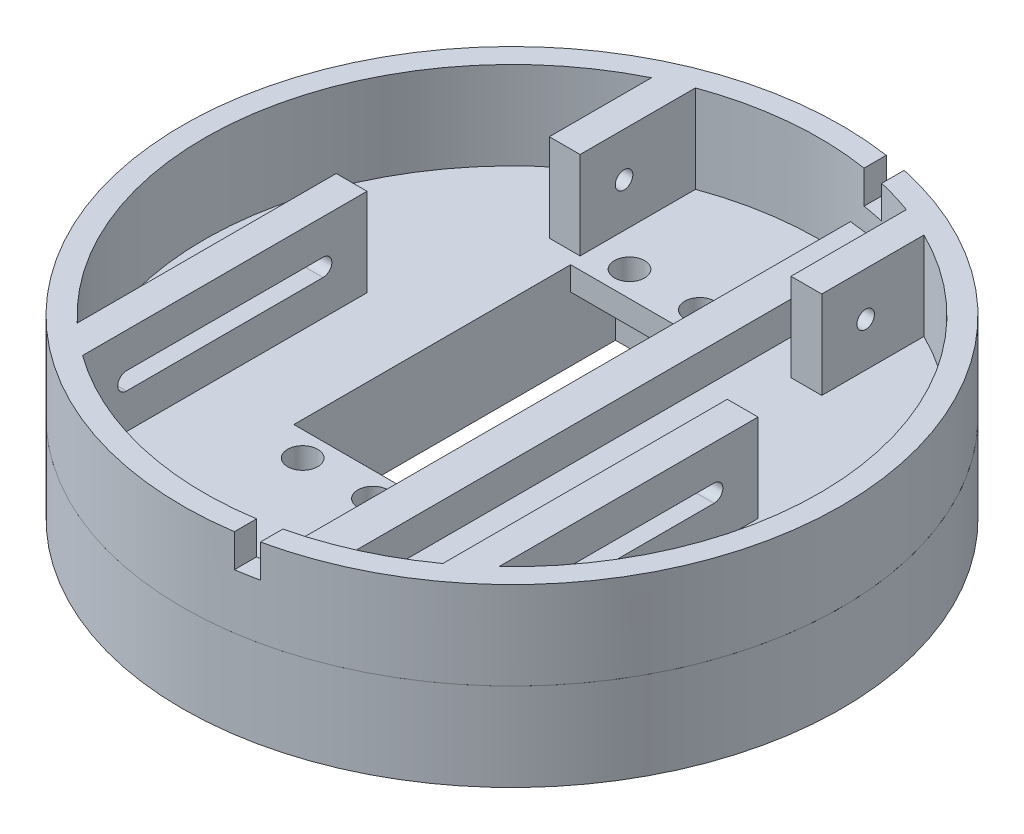
from build123d import *

# Parameters (mm, degrees)
SKETCH1_R           = 47.625
BOSS_EXTRUDE1_DEPTH = 12.7
SKETCH2_R           = 47.625
BOSS_EXTRUDE4_DEPTH = 12.7
CUT_EXTRUDE8_START  = -34.925
SKETCH8_R           = 1.27
CUT_EXTRUDE8_DEPTH  = 4.445
CUT_EXTRUDE15_DEPTH = 4.445
BOSS_EXTRUDE5_DEPTH = 4.7625
CUT_EXTRUDE10_DEPTH = 4.7625
SKETCH14_W          = 19.812
SKETCH14_H          = 52.959
CUT_EXTRUDE11_DEPTH = 9.275815586
SKETCH15_W          = 19.812
SKETCH15_H          = 40.005
CUT_EXTRUDE12_DEPTH = 8.186684
CUT_EXTRUDE13_START = -3.424185
SKETCH16_R          = 2.1844
CUT_EXTRUDE13_DEPTH = 3.424185


with BuildPart() as part:
    # Sketch1 → Boss-Extrude1 (new body)
    with BuildSketch(Plane(origin=(0, 0, 0), x_dir=(1, 0, 0), z_dir=(0, 1, 0))):
        Circle(SKETCH1_R)
    extrude(amount=-BOSS_EXTRUDE1_DEPTH)

    # Sketch14 → Cut-Extrude11 (cut)
    with BuildSketch(Plane.XZ.offset(12.7)):
        with Locations((-4.92125, -3.302)):
            Rectangle(SKETCH14_W, SKETCH14_H)
    extrude(amount=-CUT_EXTRUDE11_DEPTH, mode=Mode.SUBTRACT)

    # Sketch15 → Cut-Extrude12 (cut)
    with BuildSketch(Plane.XZ.offset(3.424184414)):
        with Locations((-4.92125, -3.302)):
            Rectangle(SKETCH15_W, SKETCH15_H)
    extrude(amount=-CUT_EXTRUDE12_DEPTH, mode=Mode.SUBTRACT)

    # Sketch16 → Cut-Extrude13 (cut)
    with BuildSketch(Plane.XZ.offset(3.424184414).offset(CUT_EXTRUDE13_START)):
        with Locations((-10.00125, -26.9875)):
            Circle(SKETCH16_R)
        with Locations((0.15875, -26.9875)):
            Circle(SKETCH16_R)
        with Locations((-10.00125, 20.2565)):
            Circle(SKETCH16_R)
        with Locations((0.15875, 20.2565)):
            Circle(SKETCH16_R)
    extrude(amount=CUT_EXTRUDE13_DEPTH, mode=Mode.SUBTRACT)


with BuildPart() as body_2:
    # Sketch2 → Boss-Extrude4 (new body)
    with BuildSketch(Plane(origin=(0, 0, 0), x_dir=(1, 0, 0), z_dir=(0, 1, 0))):
        Circle(SKETCH2_R)
        with BuildLine():
            Line((30.48, 5.08), (26.035, 5.08))
            Line((26.035, 5.08), (26.035, -36.027507199))
            ThreePointArc((26.035, -36.027507199), (0, -44.45), (-26.035, -36.027507199))
            Line((-26.035, -36.027507199), (-26.035, 5.08))
            Line((-26.035, 5.08), (-30.48, 5.08))
            Line((-30.48, 5.08), (-30.48, -32.353857575))
            ThreePointArc((-30.48, -32.353857575), (-43.961440483, 6.572233308), (-19.685, 39.853522743))
            Line((-19.685, 39.853522743), (-19.685, 25.0825))
            Line((-19.685, 25.0825), (-15.24, 25.0825))
            Line((-15.24, 25.0825), (-15.24, 41.755776846))
            ThreePointArc((-15.24, 41.755776846), (0, 44.45), (15.24, 41.755776846))
            Line((15.24, 41.755776846), (15.24, 25.0825))
            Line((15.24, 25.0825), (19.685, 25.0825))
            Line((19.685, 25.0825), (19.685, 39.853522743))
            ThreePointArc((19.685, 39.853522743), (43.961440483, 6.572233308), (30.48, -32.353857575))
            Line((30.48, -32.353857575), (30.48, 5.08))
        make_face(mode=Mode.SUBTRACT)
    extrude(amount=BOSS_EXTRUDE4_DEPTH)

    # Sketch8 → Cut-Extrude8 (cut)
    with BuildSketch(Plane.ZY.offset(15.24).offset(CUT_EXTRUDE8_START)):
        with Locations((-31.4325, 6.35)):
            Circle(SKETCH8_R)
    cut_extrude8 = extrude(amount=CUT_EXTRUDE8_DEPTH, mode=Mode.SUBTRACT)

    # Sketch17 → Cut-Extrude15 (cut)
    with BuildSketch(Plane(origin=(-26.035, 0, 0), x_dir=(0, 0, -1), z_dir=(1, 0, 0))):
        with BuildLine():
            Line((-29.677507199, 7.62), (-1.27, 7.62))
            ThreePointArc((-1.27, 7.62), (0, 6.35), (-1.27, 5.08))
            Line((-1.27, 5.08), (-29.677507199, 5.08))
            ThreePointArc((-29.677507199, 5.08), (-30.947507199, 6.35), (-29.677507199, 7.62))
        make_face()
    cut_extrude15 = extrude(amount=-CUT_EXTRUDE15_DEPTH, mode=Mode.SUBTRACT)

    # Mirror4: Cut-Extrude8, Cut-Extrude15 across plane
    add(cut_extrude8.mirror(Plane(origin=(0, 0, 0), x_dir=(0, 0, 1), z_dir=(1, 0, 0))), mode=Mode.SUBTRACT)
    add(cut_extrude15.mirror(Plane(origin=(0, 0, 0), x_dir=(0, 0, 1), z_dir=(1, 0, 0))), mode=Mode.SUBTRACT)

    # Sketch12 → Cut-Extrude10 (cut)
    with BuildSketch(Plane(origin=(0, 12.7, 0), x_dir=(1, 0, 0), z_dir=(0, 1, 0))):
        with BuildLine():
            Line((10.16, -46.528647358), (10.16, 46.528647358))
            ThreePointArc((10.16, 46.528647358), (8.577426405, 46.846220565), (6.985, 47.109981957))
            Line((6.985, 47.109981957), (6.985, -47.109981957))
            ThreePointArc((6.985, -47.109981957), (8.577426405, -46.846220565), (10.16, -46.528647358))
        make_face()
    extrude(amount=-CUT_EXTRUDE10_DEPTH, mode=Mode.SUBTRACT)


with BuildPart() as body_3:
    # Sketch10 → Boss-Extrude5 (new body)
    with BuildSketch(Plane(origin=(0, 0, 0), x_dir=(1, 0, 0), z_dir=(0, 1, 0))):
        with BuildLine():
            ThreePointArc((4.7625, -44.19412963), (7.475442585, -43.816894666), (10.16, -43.273281595))
            Line((10.16, -43.273281595), (10.16, 43.273281595))
            ThreePointArc((10.16, 43.273281595), (7.475442585, 43.816894666), (4.7625, 44.19412963))
            Line((4.7625, 44.19412963), (4.7625, -44.19412963))
        make_face()
    extrude(amount=BOSS_EXTRUDE5_DEPTH)


solid = Compound([part.part, body_2.part, body_3.part])
